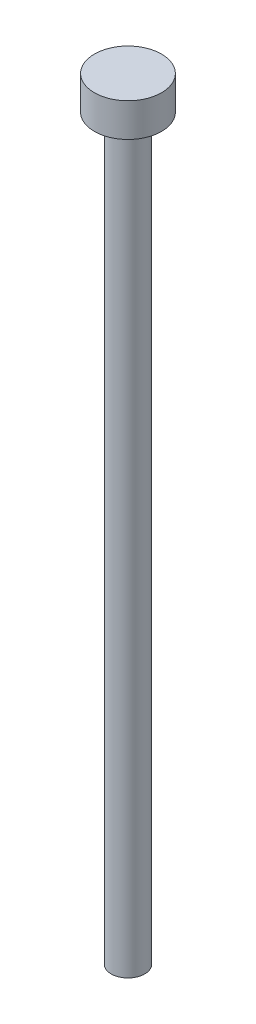
from build123d import *

# Parameters (mm, degrees)
SKETCH1_R           = 1.5
BOSS_EXTRUDE1_DEPTH = 66
SKETCH2_R           = 3
BOSS_EXTRUDE2_DEPTH = 3
FILLET1_R           = 1


with BuildPart() as part:
    # Sketch1 → Boss-Extrude1 (new body)
    with BuildSketch(Plane(origin=(0, 0, 0), x_dir=(1, 0, 0), z_dir=(0, 1, 0))):
        Circle(SKETCH1_R)
    extrude(amount=BOSS_EXTRUDE1_DEPTH)

    # Sketch2 → Boss-Extrude2 (add)
    with BuildSketch(Plane(origin=(0, 66, 0), x_dir=(1, 0, 0), z_dir=(0, 1, 0))):
        Circle(SKETCH2_R)
    extrude(amount=BOSS_EXTRUDE2_DEPTH)

    # Fillet1
    fillet1_edges = [part.edges().sort_by_distance(p)[0] for p in [
        (-1.5, 66, 0),
    ]]
    fillet(fillet1_edges, radius=FILLET1_R)


solid = part.part
